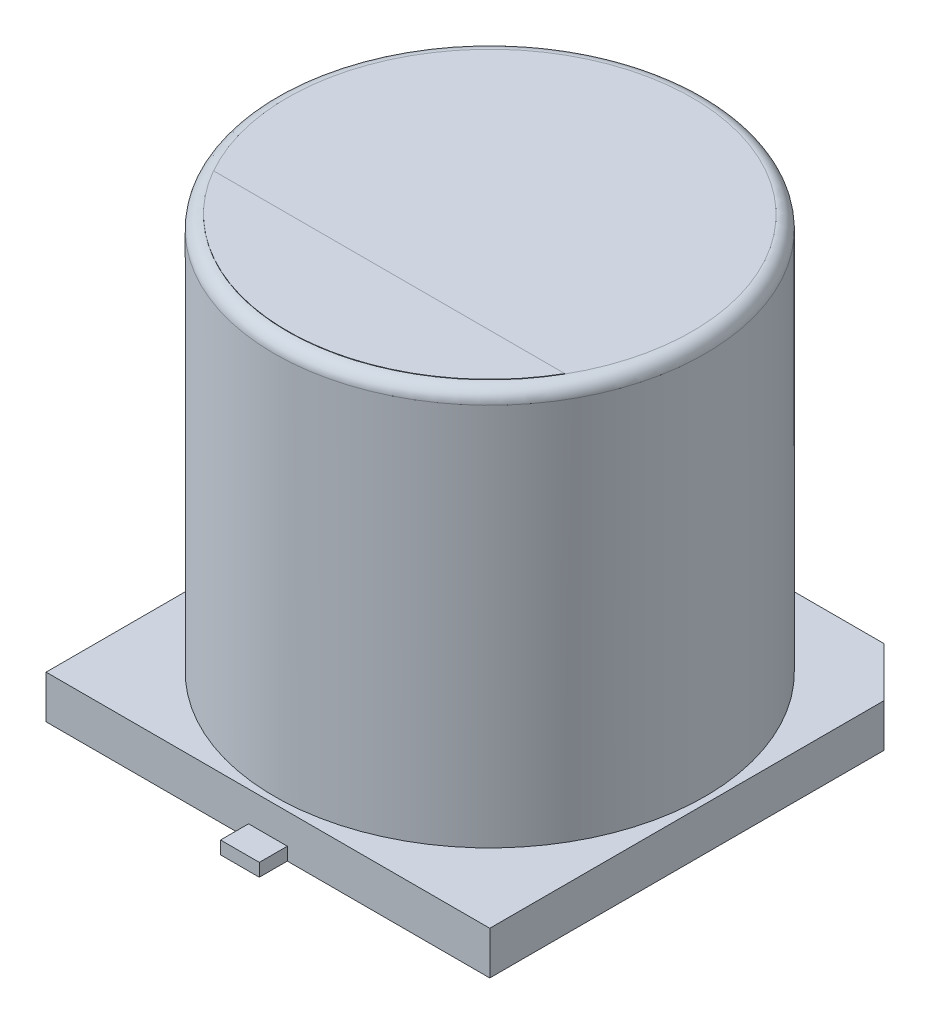
from build123d import *

# Parameters (mm, degrees)
BOSS_EXTRUDE1_DEPTH = 1
SKETCH3_R           = 5
BOSS_EXTRUDE2_DEPTH = 10.2
FILLET1_R           = 0.3
SKETCH4_W           = 0.9
SKETCH4_H           = 3.5
BOSS_EXTRUDE3_DEPTH = 0.3
BOSS_EXTRUDE4_DEPTH = 0.01


with BuildPart() as part:
    # Sketch2 → Boss-Extrude1 (new body)
    with BuildSketch(Plane(origin=(0, 0, 0), x_dir=(1, 0, 0), z_dir=(0, 1, 0))):
        Polygon((5.15, -5.15), (-5.15, -5.15), (-5.15, 4), (-4, 5.15), (4, 5.15), (5.15, 4), align=None)
    extrude(amount=BOSS_EXTRUDE1_DEPTH)

    # Sketch3 → Boss-Extrude2 (add)
    with BuildSketch(Plane(origin=(0, 0, 0), x_dir=(1, 0, 0), z_dir=(0, 1, 0))):
        Circle(SKETCH3_R)
    extrude(amount=BOSS_EXTRUDE2_DEPTH)

    # Fillet1
    fillet1_edges = [part.edges().sort_by_distance(p)[0] for p in [
        (-5, 10.2, 0),
    ]]
    fillet(fillet1_edges, radius=FILLET1_R)

    # Sketch4 → Boss-Extrude3 (add)
    with BuildSketch(Plane(origin=(0, 0, 0), x_dir=(1, 0, 0), z_dir=(0, 1, 0))):
        with Locations((0, 4.05)):
            Rectangle(SKETCH4_W, SKETCH4_H)
        with Locations((0, -4.05)):
            Rectangle(SKETCH4_W, SKETCH4_H)
    extrude(amount=BOSS_EXTRUDE3_DEPTH)

    # Sketch5 → Boss-Extrude4 (add)
    with BuildSketch(Plane(origin=(0, 10.2, 0), x_dir=(1, 0, 0), z_dir=(0, 1, 0))):
        with BuildLine():
            Line((-4.077855221, -2.336898969), (4.077855221, -2.336898969))
            ThreePointArc((4.077855221, -2.336898969), (0, -4.7), (-4.077855221, -2.336898969))
        make_face()
    extrude(amount=BOSS_EXTRUDE4_DEPTH)


solid = part.part
